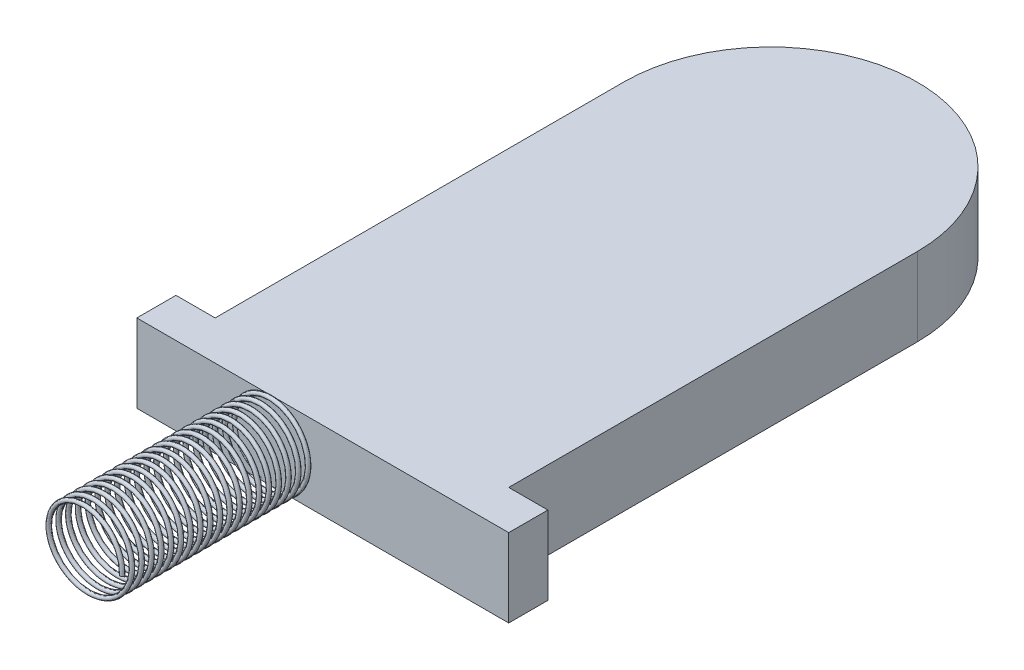
from build123d import *

# Parameters (mm, degrees)
EXTRUDE_1_DEPTH = 0.4
SWEEP_1_PITCH   = 0.05
SWEEP_1_HEIGHT  = 1
SWEEP_1_RADIUS  = 0.2
SKETCH_4_R      = 0.01


with BuildPart() as part:
    # 草图1 → 凸台-拉伸1 (new body)
    with BuildSketch(Plane(origin=(0, 0, 0), x_dir=(1, 0, 0), z_dir=(0, 1, 0))):
        with BuildLine():
            Line((-0.5, -1.08746067), (-0.7, -1.08746067))
            Line((-0.7, -1.08746067), (-0.7, -1.28746067))
            Line((-0.7, -1.28746067), (1.2, -1.28746067))
            Line((1.2, -1.28746067), (1.2, -1.08746067))
            Line((1.2, -1.08746067), (1, -1.08746067))
            Line((1, -1.08746067), (1, 1))
            ThreePointArc((1, 1), (0.25, 1.75), (-0.5, 1))
            Line((-0.5, 1), (-0.5, -1.08746067))
        make_face()
    extrude(amount=EXTRUDE_1_DEPTH)

    # 扫描1: sweep along a helix
    with BuildLine() as sweep_1_path:
        Helix(SWEEP_1_PITCH, SWEEP_1_HEIGHT, SWEEP_1_RADIUS, center=(0, 0.2, 1.28746067), direction=(0, 0, 1), lefthand=True)
    # 草图4 → 扫描1 (sweep)
    with BuildSketch(Plane.XZ.offset(-0.2)):
        with Locations((-0.2, 1.28746067)):
            Circle(SKETCH_4_R)
    sweep(path=sweep_1_path.line, is_frenet=True)


solid = part.part
